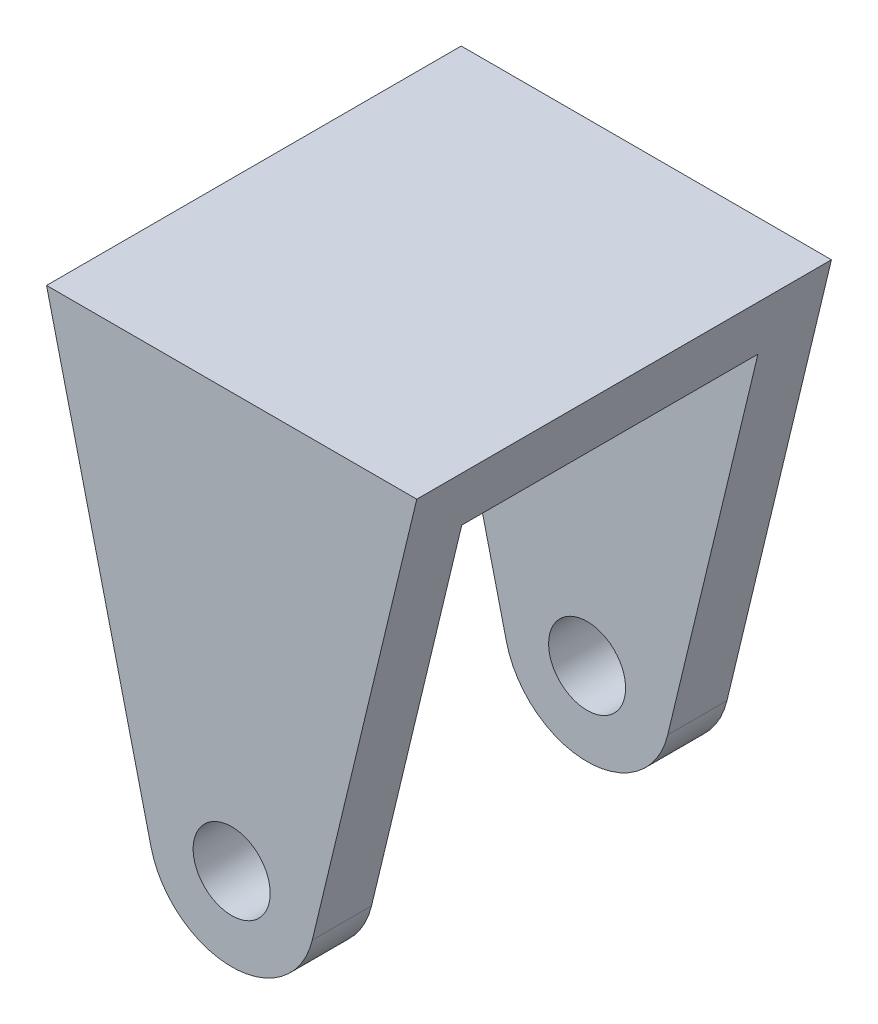
from build123d import *

# Parameters (mm, degrees)
SKETCH1_R               = 26
BOSS_EXTRUDE1_DEPTH     = 140
SKETCH2_W               = 200
SKETCH2_H               = 296
CUT_EXTRUDE1_DEPTH      = 126
CUT_EXTRUDE1_DEPTH_BACK = 126


with BuildPart() as part:
    # Sketch1 → Boss-Extrude1 (new body, symmetric)
    with BuildSketch(Plane.XY):
        with BuildLine():
            Line((125, 280), (-125, 280))
            Line((-125, 280), (-54.44483322, -13.105729116))
            ThreePointArc((-54.44483322, -13.105729116), (0, -56), (54.44483322, -13.105729116))
            Line((54.44483322, -13.105729116), (125, 280))
        make_face()
        Circle(SKETCH1_R, mode=Mode.SUBTRACT)
    extrude(amount=BOSS_EXTRUDE1_DEPTH, both=True)

    # Sketch2 → Cut-Extrude1 (cut, two sides)
    with BuildSketch(Plane(origin=(0, 0, 0), x_dir=(0, 0, -1), z_dir=(1, 0, 0))) as cut_extrude1_sk:
        with Locations((0, 92)):
            Rectangle(SKETCH2_W, SKETCH2_H)
    extrude(amount=CUT_EXTRUDE1_DEPTH, mode=Mode.SUBTRACT)
    extrude(cut_extrude1_sk.sketch, amount=-CUT_EXTRUDE1_DEPTH_BACK, mode=Mode.SUBTRACT)


solid = part.part
